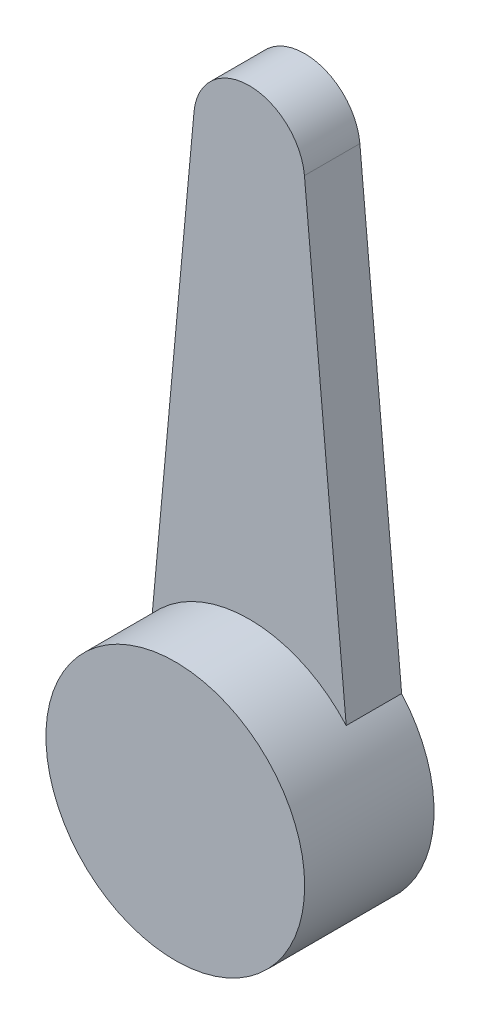
from build123d import *

# Parameters (mm, degrees)
BOSS_EXTRUDE1_DEPTH = 1.5
SKETCH2_R           = 3.5
BOSS_EXTRUDE2_DEPTH = 2


with BuildPart() as part:
    # Sketch1 → Boss-Extrude1 (new body)
    with BuildSketch(Plane.XY):
        with BuildLine():
            Line((2.623658817, 2.316552269), (1.493731251, 14.636992517))
            ThreePointArc((1.493731251, 14.636992517), (0, 16), (-1.493731251, 14.636992517))
            Line((-1.493731251, 14.636992517), (-2.623658817, 2.316552269))
            ThreePointArc((-2.623658817, 2.316552269), (0, -3.5), (2.623658817, 2.316552269))
        make_face()
    extrude(amount=BOSS_EXTRUDE1_DEPTH)

    # Sketch2 → Boss-Extrude2 (add)
    with BuildSketch(Plane.XY.offset(1.5)):
        Circle(SKETCH2_R)
    extrude(amount=BOSS_EXTRUDE2_DEPTH)


solid = part.part
